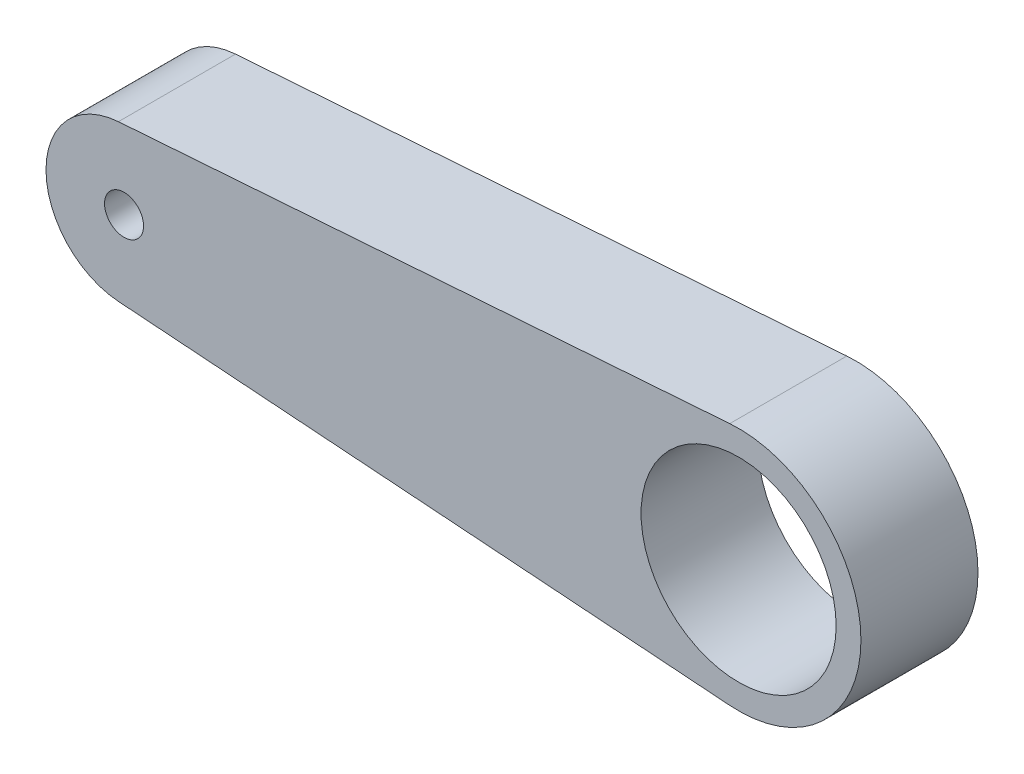
from build123d import *

# Parameters (mm, degrees)
CROQUIS2_R              = 0.5
CROQUIS2_R_2            = 2.5
SALIENTE_EXTRUIR1_DEPTH = 1.5


with BuildPart() as part:
    # Croquis2 → Saliente-Extruir1 (new body, symmetric)
    with BuildSketch(Plane.XY):
        with BuildLine():
            Line((15.52392639, 3.127409494), (-0.144199369, 1.994794862))
            ThreePointArc((-0.144199369, 1.994794862), (-2, 0), (-0.144199369, -1.994794862))
            Line((-0.144199369, -1.994794862), (15.52392639, -3.127409494))
            ThreePointArc((15.52392639, -3.127409494), (18.885570031, 0), (15.52392639, 3.127409494))
        make_face()
        Circle(CROQUIS2_R, mode=Mode.SUBTRACT)
        with Locations((15.75, 0)):
            Circle(CROQUIS2_R_2, mode=Mode.SUBTRACT)
    extrude(amount=SALIENTE_EXTRUIR1_DEPTH, both=True)


solid = part.part
